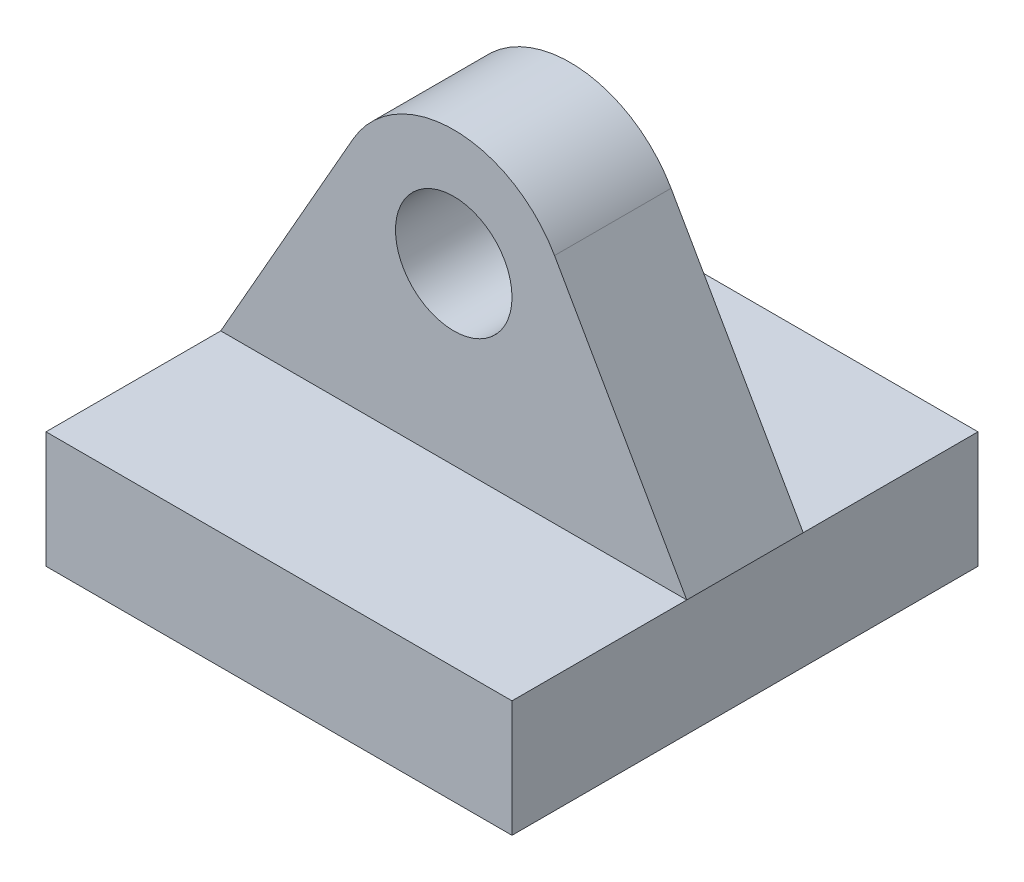
from build123d import *

# Parameters (mm, degrees)
SKETCH1_W           = 25.4
SKETCH1_H           = 6.35
BOSS_EXTRUDE1_DEPTH = 12.7
SKETCH2_R           = 3.175
BOSS_EXTRUDE2_DEPTH = 3.175


with BuildPart() as part:
    # Sketch1 → Boss-Extrude1 (new body, symmetric)
    with BuildSketch(Plane.XY):
        Rectangle(SKETCH1_W, SKETCH1_H)
    extrude(amount=BOSS_EXTRUDE1_DEPTH, both=True)

    # Sketch2 → Boss-Extrude2 (add, symmetric)
    with BuildSketch(Plane.XY):
        with BuildLine():
            Line((-12.7, 3.175), (-5.493685279, 15.828674269))
            ThreePointArc((-5.493685279, 15.828674269), (0, 19.022118366), (5.493685279, 15.828674269))
            Line((5.493685279, 15.828674269), (12.7, 3.175))
            Line((12.7, 3.175), (-12.7, 3.175))
        make_face()
        with Locations((0, 12.7)):
            Circle(SKETCH2_R, mode=Mode.SUBTRACT)
    extrude(amount=BOSS_EXTRUDE2_DEPTH, both=True)


solid = part.part
